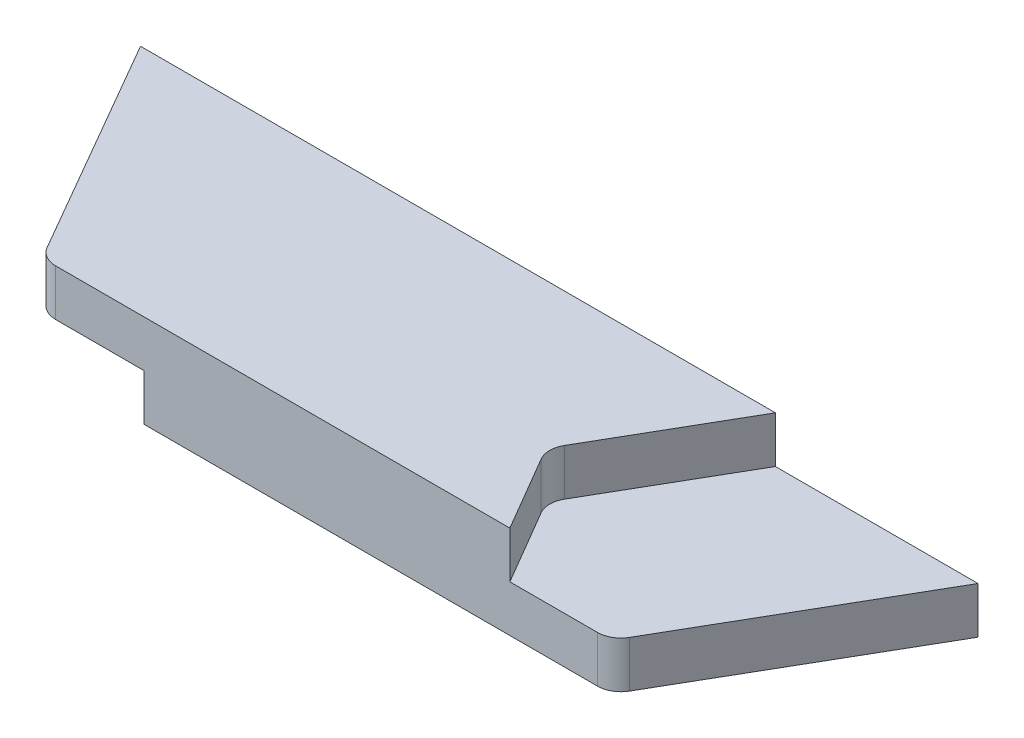
from build123d import *

# Parameters (mm, degrees)
SKETCH_1_W          = 50
SKETCH_1_H          = 20
EXTRUDE_1_DEPTH     = 180
CUT_EXTRUDE_1_DEPTH = 10
CUT_EXTRUDE_2_DEPTH = 10
SKETCH_4_OUTSIDE_W  = 219.576
SKETCH_4_OUTSIDE_H  = 89.576
CUT_EXTRUDE_4_DEPTH = 21


with BuildPart() as part:
    # Эскиз1 → Бобышка-Вытянуть1 (new body)
    with BuildSketch(Plane(origin=(0, 0, 0), x_dir=(0, 0, -1), z_dir=(1, 0, 0))):
        with Locations((25, 10)):
            Rectangle(SKETCH_1_W, SKETCH_1_H)
    extrude(amount=EXTRUDE_1_DEPTH)

    # Эскиз2 → Вырез-Вытянуть1 (cut)
    with BuildSketch(Plane.XZ):
        with BuildLine():
            Line((43.517527849, -50), (0, -50))
            Line((0, -50), (0, 0))
            Line((0, 0), (50.69898236, 0))
            Line((50.69898236, 0), (60.088568146, -16.308535178))
            ThreePointArc((60.088568146, -16.308535178), (60.755434633, -18.806330829), (60.085562557, -21.303322104))
            Line((60.085562557, -21.303322104), (43.517527849, -50))
        make_face()
    extrude(amount=-CUT_EXTRUDE_1_DEPTH, mode=Mode.SUBTRACT)

    # Эскиз3 → Вырез-Вытянуть2 (cut)
    with BuildSketch(Plane(origin=(0, 20, 0), x_dir=(1, 0, 0), z_dir=(0, 1, 0))):
        with BuildLine():
            Line((119.870060572, 21.260602823), (136.462759268, 50))
            Line((136.462759268, 50), (180, 50))
            Line((180, 50), (180, 0))
            Line((180, 0), (129.384239064, 0))
            Line((129.384239064, 0), (119.884637949, 16.23552237))
            ThreePointArc((119.884637949, 16.23552237), (119.200208629, 18.746098263), (119.870060572, 21.260602823))
        make_face()
    extrude(amount=-CUT_EXTRUDE_2_DEPTH, mode=Mode.SUBTRACT)

    # Эскиз4 outside → Вырез-Вытянуть4 (cut, through all)
    with BuildSketch(Plane(origin=(0, 20, 0), x_dir=(1, 0, 0), z_dir=(0, 1, 0))):
        with Locations((90, 25)):
            Rectangle(SKETCH_4_OUTSIDE_W, SKETCH_4_OUTSIDE_H)
        with BuildLine():
            Line((180, 50), (152.575862213, 2.5))
            ThreePointArc((152.575862213, 2.5), (150.745735195, 0.669872981), (148.245735195, 0))
            Line((148.245735195, 0), (31.754264805, 0))
            ThreePointArc((31.754264805, 0), (29.254264805, 0.669872981), (27.424137787, 2.5))
            Line((27.424137787, 2.5), (0, 50))
            Line((0, 50), (180, 50))
        make_face(mode=Mode.SUBTRACT)
    extrude(amount=-CUT_EXTRUDE_4_DEPTH, mode=Mode.SUBTRACT)


solid = part.part
